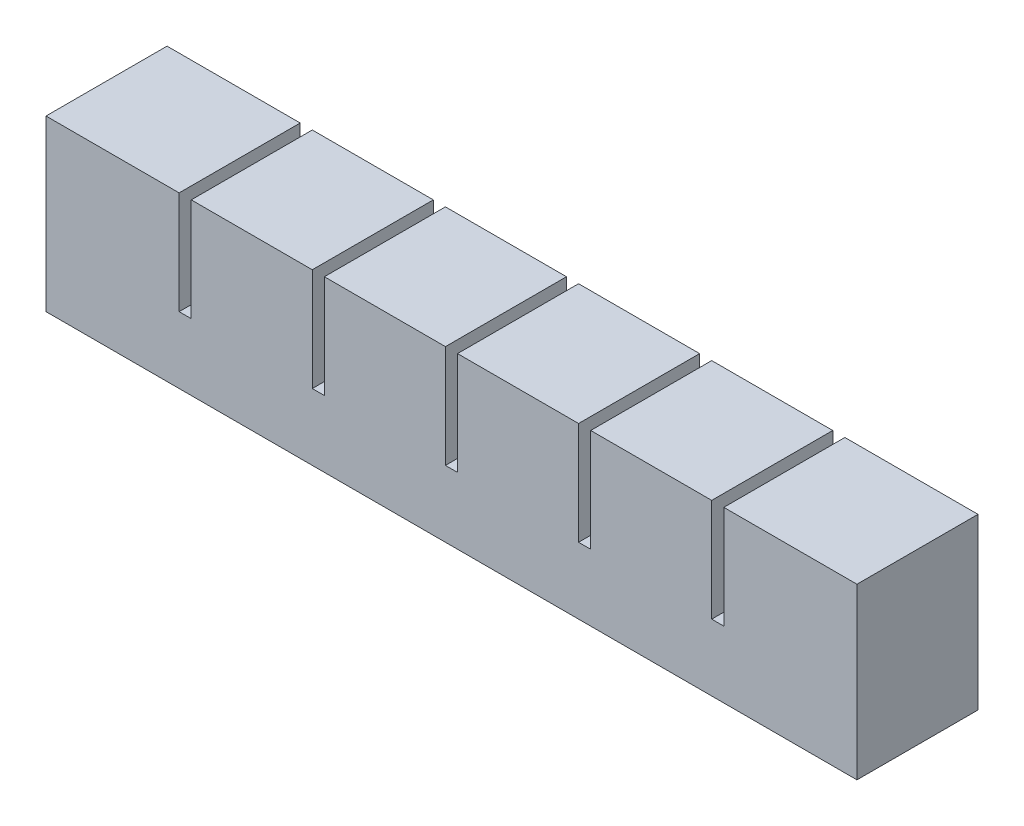
from build123d import *

# Parameters (mm, degrees)
SKETCH1_W           = 20
SKETCH1_H           = 22
BOSS_EXTRUDE1_DEPTH = 20
SKETCH2_W           = 8
SKETCH2_H           = 8
CUT_EXTRUDE1_DEPTH  = 16
SKETCH3_W           = 20
SKETCH3_H           = 5
BOSS_EXTRUDE2_DEPTH = 2
LPATTERN1_COUNT     = 6
LPATTERN1_PITCH     = 22
SKETCH4_W           = 20
SKETCH4_H           = 17
BOSS_EXTRUDE3_DEPTH = 2
SKETCH5_W           = 20
SKETCH5_H           = 22
BOSS_EXTRUDE4_DEPTH = 2
SKETCH6_W           = 118
SKETCH6_H           = 2
CUT_EXTRUDE2_DEPTH  = 2
SKETCH7_W           = 134
SKETCH7_H           = 20
BOSS_EXTRUDE5_DEPTH = 6


with BuildPart() as part:
    # Sketch1 → Boss-Extrude1 (new body)
    with BuildSketch(Plane.XY):
        with Locations((10, 11)):
            Rectangle(SKETCH1_W, SKETCH1_H)
    extrude(amount=BOSS_EXTRUDE1_DEPTH)

    # Sketch2 → Cut-Extrude1 (cut)
    with BuildSketch(Plane(origin=(0, 0, 0), x_dir=(-1, 0, 0), z_dir=(0, -1, 0))):
        with Locations((-10, -10)):
            Rectangle(SKETCH2_W, SKETCH2_H)
    extrude(amount=-CUT_EXTRUDE1_DEPTH, mode=Mode.SUBTRACT)

    # Sketch3 → Boss-Extrude2 (add)
    with BuildSketch(Plane(origin=(20, 0, 0), x_dir=(0, 0, -1), z_dir=(1, 0, 0))):
        with Locations((-10, 2.5)):
            Rectangle(SKETCH3_W, SKETCH3_H)
    extrude(amount=BOSS_EXTRUDE2_DEPTH)


with BuildPart() as lpattern1_1:
    # LPattern1: pattern copy
    add(part.part.moved(Location(Vector(1, 0, 0) * (1 * LPATTERN1_PITCH))))


with BuildPart() as lpattern1_2:
    # LPattern1: pattern copy
    add(part.part.moved(Location(Vector(1, 0, 0) * (2 * LPATTERN1_PITCH))))


with BuildPart() as lpattern1_3:
    # LPattern1: pattern copy
    add(part.part.moved(Location(Vector(1, 0, 0) * (3 * LPATTERN1_PITCH))))


with BuildPart() as lpattern1_4:
    # LPattern1: pattern copy
    add(part.part.moved(Location(Vector(1, 0, 0) * (4 * LPATTERN1_PITCH))))


with BuildPart() as lpattern1_5:
    # LPattern1: pattern copy
    add(part.part.moved(Location(Vector(1, 0, 0) * (5 * LPATTERN1_PITCH))))


with BuildPart() as lpattern1_1_1:
    add(lpattern1_1.part)

    # Combine1: union LPattern1_2, LPattern1_3, LPattern1_4, LPattern1_5, part
    add(lpattern1_2.part)
    add(lpattern1_3.part)
    add(lpattern1_4.part)
    add(lpattern1_5.part)
    add(part.part)

    # Sketch4 → Boss-Extrude3 (add)
    with BuildSketch(Plane(origin=(130, 0, 0), x_dir=(0, 0, -1), z_dir=(1, 0, 0))):
        with Locations((-10, 13.5)):
            Rectangle(SKETCH4_W, SKETCH4_H)
    extrude(amount=BOSS_EXTRUDE3_DEPTH)

    # Sketch5 → Boss-Extrude4 (add)
    with BuildSketch(Plane.ZY):
        with Locations((10, 11)):
            Rectangle(SKETCH5_W, SKETCH5_H)
    extrude(amount=BOSS_EXTRUDE4_DEPTH)

    # Sketch6 → Cut-Extrude2 (cut)
    with BuildSketch(Plane.XZ):
        with Locations((65, 10)):
            Rectangle(SKETCH6_W, SKETCH6_H)
    extrude(amount=-CUT_EXTRUDE2_DEPTH, mode=Mode.SUBTRACT)

    # Sketch7 → Boss-Extrude5 (add)
    with BuildSketch(Plane(origin=(0, 0, 0), x_dir=(-1, 0, 0), z_dir=(0, -1, 0))):
        with Locations((-65, -10)):
            Rectangle(SKETCH7_W, SKETCH7_H)
    extrude(amount=BOSS_EXTRUDE5_DEPTH)


solid = lpattern1_1_1.part
